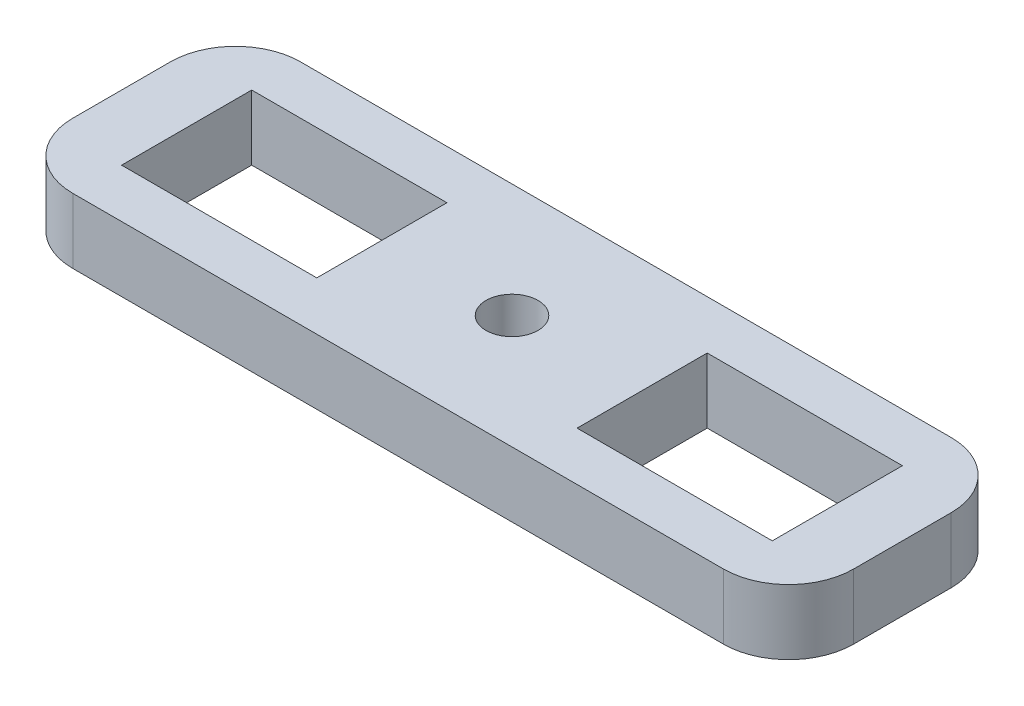
from build123d import *

# Parameters (mm, degrees)
SKETCH1_R           = 4
SKETCH1_W           = 30
SKETCH1_H           = 20
BOSS_EXTRUDE1_DEPTH = 10


with BuildPart() as part:
    # Sketch1 → Boss-Extrude1 (new body)
    with BuildSketch(Plane(origin=(0, 0, 0), x_dir=(1, 0, 0), z_dir=(0, 1, 0))):
        with BuildLine():
            Line((10, 0), (110, 0))
            ThreePointArc((110, 0), (117.071067812, 2.928932188), (120, 10))
            Line((120, 10), (120, 25))
            ThreePointArc((120, 25), (117.071067812, 32.071067812), (110, 35))
            Line((110, 35), (10, 35))
            ThreePointArc((10, 35), (2.928932188, 32.071067812), (0, 25))
            Line((0, 25), (0, 10))
            ThreePointArc((0, 10), (2.928932188, 2.928932188), (10, 0))
        make_face()
        with Locations((60, 17.5)):
            Circle(SKETCH1_R, mode=Mode.SUBTRACT)
        with Locations((25, 17.5)):
            Rectangle(SKETCH1_W, SKETCH1_H, mode=Mode.SUBTRACT)
        with Locations((95, 17.5)):
            Rectangle(SKETCH1_W, SKETCH1_H, mode=Mode.SUBTRACT)
    extrude(amount=BOSS_EXTRUDE1_DEPTH)


solid = part.part
